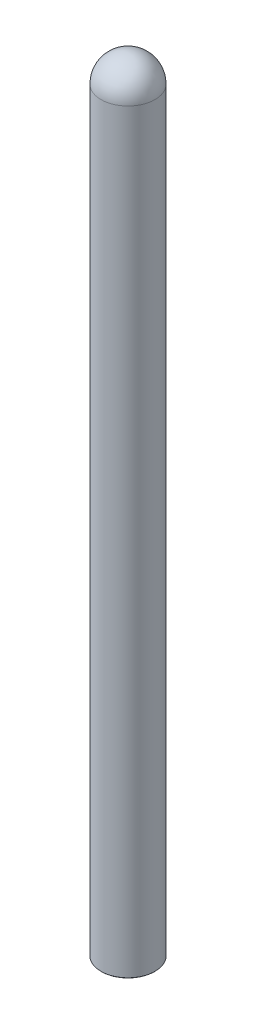
from build123d import *

# Parameters (mm, degrees)
THICKEN1_T2   = 0.5
CHAMFER1_SIZE = 0.02
CHAMFER2_SIZE = 0.02


with BuildPart() as body_1:
    # Surface-Revolve1: a surface, the sketch's curves turned about an axis
    with BuildLine(Plane.XY, mode=Mode.PRIVATE) as surface_revolve1_1_path:
        Line((-1, 0), (-1, 28))
        ThreePointArc((-1, 28), (-0.707106781, 28.707106781), (0, 29))
    surface_revolve1_1 = Shell.revolve(surface_revolve1_1_path.wire(), 360, Axis((0, 0, 0), (0, 1, 0)))
    add(Solid.thicken(surface_revolve1_1, -THICKEN1_T2))

    # Chamfer1
    chamfer1_edges = [body_1.edges().sort_by_distance(p)[0] for p in [
        (1, 0, 0),
    ]]
    chamfer(chamfer1_edges, length=CHAMFER1_SIZE)

    # Chamfer2
    chamfer2_edges = [body_1.edges().sort_by_distance(p)[0] for p in [
        (0.5, 0, 0),
    ]]
    chamfer(chamfer2_edges, length=CHAMFER2_SIZE)

    # Sketch4 → Revolve2 (revolve)
    with BuildSketch(Plane.XY, mode=Mode.PRIVATE) as revolve2_sk:
        with BuildLine():
            Line((-1, 28), (0, 28))
            Line((0, 28), (0, 29))
            ThreePointArc((0, 29), (-0.707106781, 28.707106781), (-1, 28))
        make_face()
    revolve(revolve2_sk.sketch.rotate(Axis((0, 0, 0), (0, 1, 0)), 90), axis=Axis((0, 0, 0), (0, 1, 0)))


solid = body_1.part
